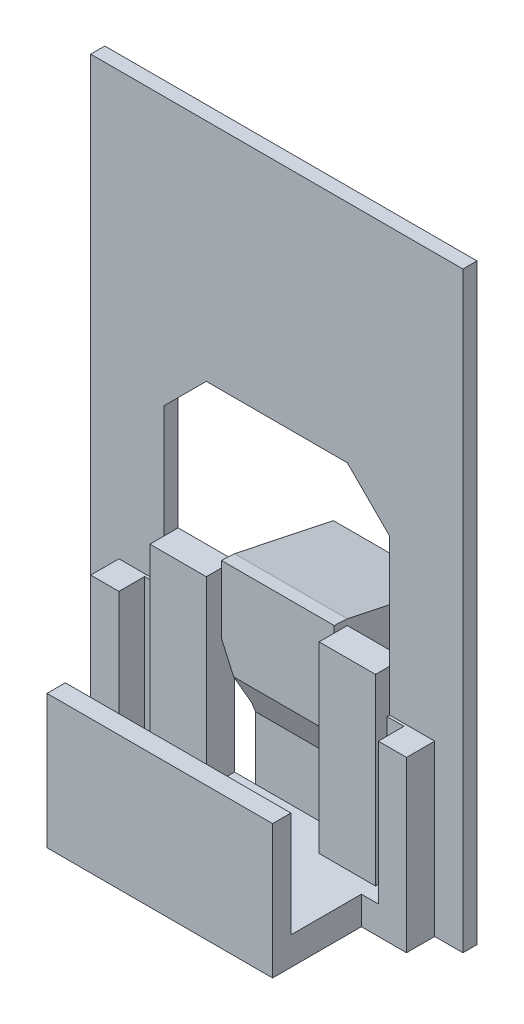
from build123d import *

# Parameters (mm, degrees)
SKETCH_1_W          = 16
SKETCH_1_H          = 6
EXTRUDE_1_DEPTH     = 2
SKETCH_1_3_W        = 16
SKETCH_1_3_H        = 2
SKETCH_1_3_H_2      = 1.5
EXTRUDE_2_DEPTH     = 15
SKETCH_2_W          = 8
SKETCH_2_H          = 26
CUT_EXTRUDE_1_DEPTH = 2
EXTRUDE_3_DEPTH     = 2.5
EXTRUDE_4_DEPTH     = 5
EXTRUDE_5_DEPTH     = 1.5
SKETCH_9_W          = 1.2
SKETCH_9_H          = 1.820432063
EXTRUDE_6_DEPTH     = 2
EXTRUDE_7_DEPTH     = 12
CUT_EXTRUDE_START   = -7.10494
CUT_EXTRUDE_2_DEPTH = 7.10494
SKETCH_12_R         = 1.281793471
CUT_EXTRUDE_3_DEPTH = 10
CUT_EXTRUDE_4_DEPTH = 20.2
SKETCH_14_W         = 5.2
SKETCH_14_H         = 1
EXTRUDE_8_DEPTH     = 30
SKETCH_14_2_W       = 5.2
SKETCH_14_2_H       = 1
EXTRUDE_9_DEPTH     = 12
SKETCH_15_W         = 1
SKETCH_15_H         = 16
EXTRUDE_10_DEPTH    = 16
CHAMFER_1_SIZE      = 3


with BuildPart() as part:
    # 草图1 → 凸台-拉伸1 (new body)
    with BuildSketch(Plane(origin=(0, 0, 0), x_dir=(1, 0, 0), z_dir=(0, 1, 0))):
        with Locations((0, -0.25)):
            Rectangle(SKETCH_1_W, SKETCH_1_H)
    extrude(amount=EXTRUDE_1_DEPTH)

    # 草图1<3> → 凸台-拉伸2 (add)
    with BuildSketch(Plane(origin=(0, 0, 0), x_dir=(1, 0, 0), z_dir=(0, 1, 0))):
        with Locations((0, 3.75)):
            Rectangle(SKETCH_1_3_W, SKETCH_1_3_H)
        with Locations((0, -4)):
            Rectangle(SKETCH_1_3_W, SKETCH_1_3_H_2)
    extrude(amount=EXTRUDE_2_DEPTH)

    # 草图2 → 切除-拉伸1 (cut)
    with BuildSketch(Plane(origin=(0, 0, -4.75), x_dir=(-1, 0, 0), z_dir=(0, 0, -1))):
        with Locations((0, 15)):
            Rectangle(SKETCH_2_W, SKETCH_2_H)
    extrude(amount=-CUT_EXTRUDE_1_DEPTH, mode=Mode.SUBTRACT)

    # 草图3 → 凸台-拉伸3 (add, symmetric)
    with BuildSketch(Plane(origin=(0, 0, 0), x_dir=(0, 0, -1), z_dir=(1, 0, 0))):
        Polygon((4.75, 0), (8.831597644, 0), (11.768525918, 13.935665169), (4.75, 15.414812878), align=None)
    extrude(amount=EXTRUDE_3_DEPTH, both=True)

    # 草图5 → 凸台-拉伸4 (add)
    with BuildSketch(Plane(origin=(2.5, 0, 0), x_dir=(0, 0, -1), z_dir=(1, 0, 0))):
        Polygon((4.75, 6.451105389), (3.822798244, 8.744995241), (3.822798244, 15.463750373), (4.75, 15.414812878), align=None)
    extrude(amount=-EXTRUDE_4_DEPTH)

    # 草图6 → 凸台-拉伸5 (add)
    with BuildSketch(Plane.ZY.offset(2.5)):
        Polygon((-4.75, 6.451105389), (-10.094945569, 5.994560313), (-11.768525918, 13.935665169), (-4.75, 15.414812878), (-3.822798244, 15.463750373), (-3.822798244, 8.744995241), align=None)
    extrude_5 = extrude(amount=EXTRUDE_5_DEPTH)

    # 草图9 → 凸台-拉伸6 (add)
    with BuildSketch(Plane.XZ):
        with Locations((8.6, -2.660216032)):
            Rectangle(SKETCH_9_W, SKETCH_9_H)
        with Locations((-8.6, -2.660216032)):
            Rectangle(SKETCH_9_W, SKETCH_9_H)
    extrude(amount=-EXTRUDE_6_DEPTH)

    # 草图9<3> → 凸台-拉伸7 (add)
    with BuildSketch(Plane.XZ):
        Polygon((8, -3.570432063), (8, -4.75), (11.2, -4.75), (11.2, -1.75), (9.2, -1.75), (9.2, -3.570432063), align=None)
        Polygon((-8, -4.75), (-8, -3.570432063), (-9.2, -3.570432063), (-9.2, -1.75), (-11.2, -1.75), (-11.2, -4.75), align=None)
    extrude(amount=-EXTRUDE_7_DEPTH)

    # 草图11 → 切除-拉伸2 (cut)
    with BuildSketch(Plane(origin=(0, -1.782098659, -8.456022034), x_dir=(-1, 0, 0), z_dir=(0, -0.206219179, -0.978505825)).offset(CUT_EXTRUDE_START)):
        Polygon((2.5, 7.947483572), (4, 11.245323919), (4, 7.947483572), (4, 5.815044055), (2.5, 5.815044055), align=None)
    cut_extrude_2 = extrude(amount=CUT_EXTRUDE_2_DEPTH, mode=Mode.SUBTRACT)

    # 镜向1: 凸台-拉伸5, 切除-拉伸2 across plane
    add(extrude_5.mirror(Plane(origin=(0, 0, 0), x_dir=(0, 0, 1), z_dir=(1, 0, 0))))
    add(cut_extrude_2.mirror(Plane(origin=(0, 0, 0), x_dir=(0, 0, 1), z_dir=(1, 0, 0))), mode=Mode.SUBTRACT)

    # 草图12 → 切除-拉伸3 (cut)
    with BuildSketch(Plane(origin=(4, 0, 0), x_dir=(0, 0, -1), z_dir=(1, 0, 0))):
        with Locations((9.183579002, 11.7521089)):
            Circle(SKETCH_12_R)
    extrude(amount=-CUT_EXTRUDE_3_DEPTH, mode=Mode.SUBTRACT)

    # 草图13 → 切除-拉伸4 (cut, through all)
    with BuildSketch(Plane(origin=(8, 0, 0), x_dir=(0, 0, -1), z_dir=(1, 0, 0))):
        Polygon((-3.25, 9.484512334), (-4.55, 9.484512334), (-4.55, 0), (-4.75, 0), (-4.75, 15), (-3.25, 15), align=None)
    extrude(amount=-CUT_EXTRUDE_4_DEPTH, mode=Mode.SUBTRACT)

    # 草图14 → 凸台-拉伸8 (add)
    with BuildSketch(Plane(origin=(0, 12, 0), x_dir=(1, 0, 0), z_dir=(0, 1, 0))):
        with Locations((10.6, 4.25)):
            Rectangle(SKETCH_14_W, SKETCH_14_H)
        with Locations((-10.6, 4.25)):
            Rectangle(SKETCH_14_W, SKETCH_14_H)
    extrude(amount=EXTRUDE_8_DEPTH)

    # 草图14<2> → 凸台-拉伸9 (add)
    with BuildSketch(Plane(origin=(0, 12, 0), x_dir=(1, 0, 0), z_dir=(0, 1, 0))):
        with Locations((10.6, 4.25)):
            Rectangle(SKETCH_14_2_W, SKETCH_14_2_H)
        with Locations((-10.6, 4.25)):
            Rectangle(SKETCH_14_2_W, SKETCH_14_2_H)
    extrude(amount=-EXTRUDE_9_DEPTH)

    # 草图15 → 凸台-拉伸10 (add)
    with BuildSketch(Plane(origin=(-8, 0, 0), x_dir=(0, 0, -1), z_dir=(1, 0, 0))):
        with Locations((4.25, 34)):
            Rectangle(SKETCH_15_W, SKETCH_15_H)
    extrude(amount=EXTRUDE_10_DEPTH)

    # 倒角1
    chamfer_1_edges = [part.edges().sort_by_distance(p)[0] for p in [
        (-8, 26, -4.25),
        (8, 26, -4.25),
    ]]
    chamfer(chamfer_1_edges, length=CHAMFER_1_SIZE)


solid = part.part
